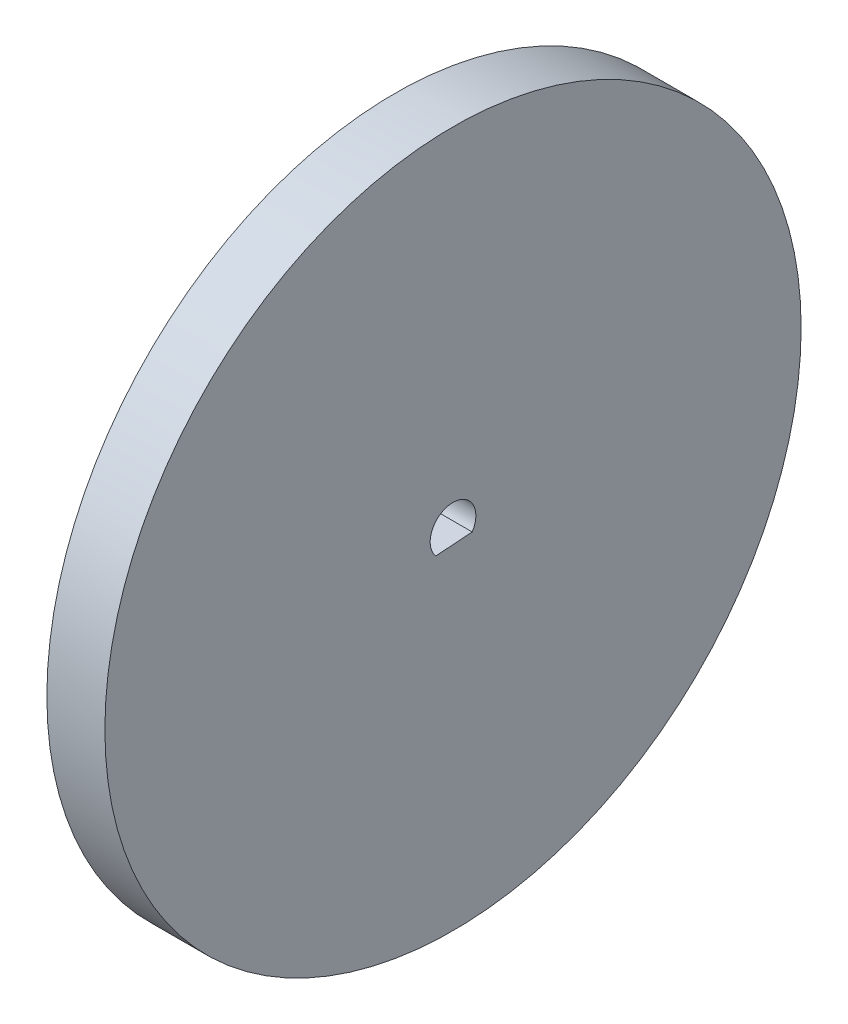
from build123d import *

# Parameters (mm, degrees)
SKETCH1_R           = 38.1
BOSS_EXTRUDE1_DEPTH = 6.35
CUT_EXTRUDE1_DEPTH  = 7.35


with BuildPart() as part:
    # Sketch1 → Boss-Extrude1 (new body)
    with BuildSketch(Plane(origin=(0, 0, 0), x_dir=(0, 0, -1), z_dir=(1, 0, 0))):
        Circle(SKETCH1_R)
    extrude(amount=BOSS_EXTRUDE1_DEPTH)

    # Sketch5 → Cut-Extrude1 (cut, through all)
    with BuildSketch(Plane(origin=(6.35, 0, 0), x_dir=(0, 0, -1), z_dir=(1, 0, 0))):
        with BuildLine():
            Line((-1.889315824, -1.637218897), (2.100738572, -1.3553219))
            ThreePointArc((2.100738572, -1.3553219), (-0.176185623, 2.493783998), (-1.889315824, -1.637218897))
        make_face()
    extrude(amount=-CUT_EXTRUDE1_DEPTH, mode=Mode.SUBTRACT)


solid = part.part
